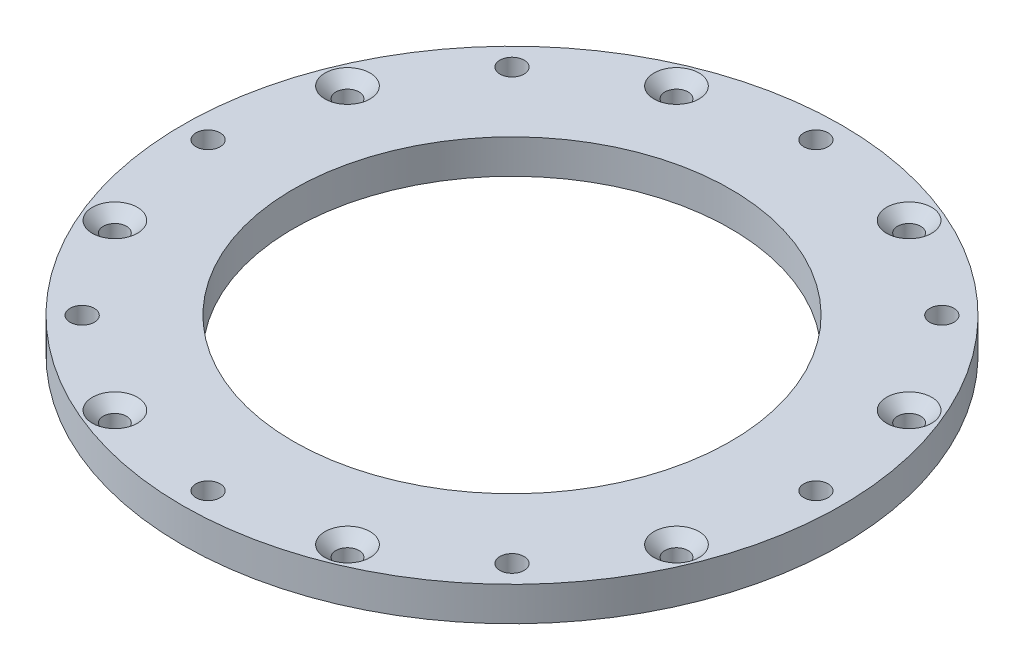
from build123d import *

# Parameters (mm, degrees)
EXTRUDE_1_DEPTH              = 5
SKETCH_2_R                   = 1.525
CUT_EXTRUDE_1_DEPTH          = 6
SKETCH_3_R                   = 48.25
EXTRUDE_2_DEPTH              = 5
SKETCH_4_R                   = 32
CUT_EXTRUDE_2_DEPTH          = 6
FILLET_1_R                   = 40
SKETCH_9_R                   = 7.5
CUT_EXTRUDE_7_DEPTH          = 6
SKETCH_15_R                  = 1.525
CUT_EXTRUDE_10_DEPTH         = 6
SKETCH_16_R                  = 1.525
SKETCH_16_R_2                = 3.525
CUT_EXTRUDE_11_DEPTH         = 6
SKETCH_17_R                  = 1.525
SKETCH_17_R_2                = 3.525
SKETCH_17_R_3                = 7.5
CUT_EXTRUDE_12_DEPTH         = 6
SKETCH_10_R                  = 1.775
CUT_EXTRUDE_13_DEPTH         = 6
SKETCH_19_R                  = 1.525
CUT_EXTRUDE_14_DEPTH         = 6
HOLE_WIZARD_M3_2_D           = 3.4
HOLE_WIZARD_M3_2_CSINK_D     = 6.6
HOLE_WIZARD_M3_2_CSINK_ANGLE = 90


with BuildPart() as part:
    # 草图1 → 凸台-拉伸1 (new body)
    with BuildSketch(Plane(origin=(0, 0, 0), x_dir=(1, 0, 0), z_dir=(0, 1, 0))):
        with BuildLine():
            ThreePointArc((-78.875, 0), (-86.526835342, -18.473164658), (-105, -26.125))
            Line((-105, -26.125), (105, -26.125))
            Line((105, -26.125), (105, 26.125))
            Line((105, 26.125), (-105, 26.125))
            ThreePointArc((-105, 26.125), (-86.526835342, 18.473164658), (-78.875, 0))
        make_face()
        with BuildLine():
            ThreePointArc((-105, 26.125), (-131.125, 0), (-105, -26.125))
            Line((-105, -26.125), (-105, 26.125))
        make_face()
        with BuildLine():
            Line((-105, 26.125), (-105, -26.125))
            ThreePointArc((-105, -26.125), (-86.526835342, -18.473164658), (-78.875, 0))
            ThreePointArc((-78.875, 0), (-86.526835342, 18.473164658), (-105, 26.125))
        make_face()
        with BuildLine():
            ThreePointArc((-105, 26.125), (-131.125, 0), (-105, -26.125))
            Line((-105, -26.125), (-105, 26.125))
        make_face()
        with BuildLine():
            Line((-105, 26.125), (-105, -26.125))
            ThreePointArc((-105, -26.125), (-86.526835342, -18.473164658), (-78.875, 0))
            ThreePointArc((-78.875, 0), (-86.526835342, 18.473164658), (-105, 26.125))
        make_face()
    extrude(amount=EXTRUDE_1_DEPTH)

    # 草图2 → 切除-拉伸1 (cut, through all)
    with BuildSketch(Plane(origin=(0, 5, 0), x_dir=(1, 0, 0), z_dir=(0, 1, 0))):
        with Locations((-91.5, 0)):
            Circle(SKETCH_2_R)
        with Locations((-98.25, -11.691342951)):
            Circle(SKETCH_2_R)
        with Locations((-111.75, -11.691342951)):
            Circle(SKETCH_2_R)
        with Locations((-118.5, 0)):
            Circle(SKETCH_2_R)
        with Locations((-111.75, 11.691342951)):
            Circle(SKETCH_2_R)
        with Locations((-98.25, 11.691342951)):
            Circle(SKETCH_2_R)
    extrude(amount=-CUT_EXTRUDE_1_DEPTH, mode=Mode.SUBTRACT)

    # 草图3 → 凸台-拉伸2 (add)
    with BuildSketch(Plane(origin=(0, 5, 0), x_dir=(1, 0, 0), z_dir=(0, 1, 0))):
        with Locations((105, 0)):
            Circle(SKETCH_3_R)
    extrude(amount=-EXTRUDE_2_DEPTH)

    # 草图4 → 切除-拉伸2 (cut, through all)
    with BuildSketch(Plane(origin=(0, 5, 0), x_dir=(1, 0, 0), z_dir=(0, 1, 0))):
        with Locations((105, 0)):
            Circle(SKETCH_4_R)
    extrude(amount=-CUT_EXTRUDE_2_DEPTH, mode=Mode.SUBTRACT)

    # 圆角1
    fillet_1_edges = [part.edges().sort_by_distance(p)[0] for p in [
        (64.43465919, 2.5, 26.125),
        (64.43465919, 2.5, -26.125),
    ]]
    fillet(fillet_1_edges, radius=FILLET_1_R)

    # 草图9 → 切除-拉伸7 (cut, through all)
    with BuildSketch(Plane(origin=(0, 5, 0), x_dir=(1, 0, 0), z_dir=(0, 1, 0))):
        with Locations((-105, 0)):
            Circle(SKETCH_9_R)
    extrude(amount=-CUT_EXTRUDE_7_DEPTH, mode=Mode.SUBTRACT)

    # 草图15 → 切除-拉伸10 (cut, through all)
    with BuildSketch(Plane(origin=(0, 5, 0), x_dir=(1, 0, 0), z_dir=(0, 1, 0))):
        with Locations((-123.619546181, 10.75)):
            Circle(SKETCH_15_R)
        with Locations((-105, 21.5)):
            Circle(SKETCH_15_R)
        with Locations((-86.380453819, 10.75)):
            Circle(SKETCH_15_R)
        with Locations((-86.380453819, -10.75)):
            Circle(SKETCH_15_R)
        with Locations((-105, -21.5)):
            Circle(SKETCH_15_R)
        with Locations((-123.619546181, -10.75)):
            Circle(SKETCH_15_R)
    extrude(amount=-CUT_EXTRUDE_10_DEPTH, mode=Mode.SUBTRACT)

    # 草图16 → 切除-拉伸11 (cut, through all)
    with BuildSketch(Plane(origin=(0, 5, 0), x_dir=(1, 0, 0), z_dir=(0, 1, 0))):
        with Locations((-111.75, 11.691342951)):
            Circle(SKETCH_16_R)
        with Locations((-111.75, 11.691342951)):
            Circle(SKETCH_16_R_2)
        with Locations((-111.75, 11.691342951)):
            Circle(SKETCH_16_R, mode=Mode.SUBTRACT)
        with Locations((-98.25, 11.691342951)):
            Circle(SKETCH_16_R_2)
        with Locations((-98.25, 11.691342951)):
            Circle(SKETCH_16_R, mode=Mode.SUBTRACT)
        with Locations((-98.25, 11.691342951)):
            Circle(SKETCH_16_R)
        with Locations((-91.5, 0)):
            Circle(SKETCH_16_R)
        with Locations((-91.5, 0)):
            Circle(SKETCH_16_R_2)
        with Locations((-91.5, 0)):
            Circle(SKETCH_16_R, mode=Mode.SUBTRACT)
        with Locations((-98.25, -11.691342951)):
            Circle(SKETCH_16_R_2)
        with Locations((-98.25, -11.691342951)):
            Circle(SKETCH_16_R, mode=Mode.SUBTRACT)
        with Locations((-111.75, -11.691342951)):
            Circle(SKETCH_16_R_2)
        with Locations((-111.75, -11.691342951)):
            Circle(SKETCH_16_R, mode=Mode.SUBTRACT)
        with Locations((-111.75, -11.691342951)):
            Circle(SKETCH_16_R)
        with Locations((-118.5, 0)):
            Circle(SKETCH_16_R_2)
        with Locations((-118.5, 0)):
            Circle(SKETCH_16_R, mode=Mode.SUBTRACT)
        with Locations((-118.5, 0)):
            Circle(SKETCH_16_R)
    extrude(amount=-CUT_EXTRUDE_11_DEPTH, mode=Mode.SUBTRACT)

    # 草图17 → 切除-拉伸12 (cut, through all)
    with BuildSketch(Plane(origin=(0, 5, 0), x_dir=(1, 0, 0), z_dir=(0, 1, 0))):
        with BuildLine():
            ThreePointArc((-105, 26.125), (-131.125, 0), (-105, -26.125))
            Line((-105, -26.125), (46.557319748, -26.125))
            ThreePointArc((46.557319748, -26.125), (60.719472559, -28.715998038), (73.046919862, -36.153328612))
            ThreePointArc((73.046919862, -36.153328612), (56.75, 0), (73.046919862, 36.153328612))
            ThreePointArc((73.046919862, 36.153328612), (60.719472559, 28.715998038), (46.557319748, 26.125))
            Line((46.557319748, 26.125), (-105, 26.125))
        make_face()
        with Locations((-105, -21.5)):
            Circle(SKETCH_17_R, mode=Mode.SUBTRACT)
        with Locations((-123.619546181, -10.75)):
            Circle(SKETCH_17_R, mode=Mode.SUBTRACT)
        with Locations((-111.75, -11.691342951)):
            Circle(SKETCH_17_R_2, mode=Mode.SUBTRACT)
        with Locations((-98.25, -11.691342951)):
            Circle(SKETCH_17_R_2, mode=Mode.SUBTRACT)
        with Locations((-118.5, 0)):
            Circle(SKETCH_17_R_2, mode=Mode.SUBTRACT)
        with Locations((-105, 0)):
            Circle(SKETCH_17_R_3, mode=Mode.SUBTRACT)
        with Locations((-86.380453819, -10.75)):
            Circle(SKETCH_17_R, mode=Mode.SUBTRACT)
        with Locations((-123.619546181, 10.75)):
            Circle(SKETCH_17_R, mode=Mode.SUBTRACT)
        with Locations((-111.75, 11.691342951)):
            Circle(SKETCH_17_R_2, mode=Mode.SUBTRACT)
        with Locations((-98.25, 11.691342951)):
            Circle(SKETCH_17_R_2, mode=Mode.SUBTRACT)
        with Locations((-91.5, 0)):
            Circle(SKETCH_17_R_2, mode=Mode.SUBTRACT)
        with Locations((-86.380453819, 10.75)):
            Circle(SKETCH_17_R, mode=Mode.SUBTRACT)
        with Locations((-105, 21.5)):
            Circle(SKETCH_17_R, mode=Mode.SUBTRACT)
    extrude(amount=-CUT_EXTRUDE_12_DEPTH, mode=Mode.SUBTRACT)

    # 草图10 → 切除-拉伸13 (cut, through all)
    with BuildSketch(Plane(origin=(0, 5, 0), x_dir=(1, 0, 0), z_dir=(0, 1, 0))):
        with Locations((73.533748237, 31.466251763)):
            Circle(SKETCH_10_R)
        with Locations((105, 44.5)):
            Circle(SKETCH_10_R)
        with Locations((136.466251763, 31.466251763)):
            Circle(SKETCH_10_R)
        with Locations((136.466251763, -31.466251763)):
            Circle(SKETCH_10_R)
        with Locations((73.533748237, -31.466251763)):
            Circle(SKETCH_10_R)
        with Locations((60.5, 0)):
            Circle(SKETCH_10_R)
        with Locations((149.5, 0)):
            Circle(SKETCH_10_R)
        with Locations((105, -44.5)):
            Circle(SKETCH_10_R)
    extrude(amount=-CUT_EXTRUDE_13_DEPTH, mode=Mode.SUBTRACT)

    # 草图19 → 切除-拉伸14 (cut, through all)
    with BuildSketch(Plane(origin=(0, 5, 0), x_dir=(1, 0, 0), z_dir=(0, 1, 0))):
        with Locations((122.02941274, 41.112639197)):
            Circle(SKETCH_19_R)
        with Locations((146.112639197, 17.02941274)):
            Circle(SKETCH_19_R)
        with Locations((146.112639197, -17.02941274)):
            Circle(SKETCH_19_R)
        with Locations((122.02941274, -41.112639197)):
            Circle(SKETCH_19_R)
        with Locations((87.97058726, -41.112639197)):
            Circle(SKETCH_19_R)
        with Locations((63.887360803, -17.02941274)):
            Circle(SKETCH_19_R)
        with Locations((63.887360803, 17.02941274)):
            Circle(SKETCH_19_R)
        with Locations((87.97058726, 41.112639197)):
            Circle(SKETCH_19_R)
    extrude(amount=-CUT_EXTRUDE_14_DEPTH, mode=Mode.SUBTRACT)

    # M3 开槽沉头木螺钉的锥形沉头孔2 (through all)
    with Locations(Plane(origin=(0, 5, 0), x_dir=(1, 0, 0), z_dir=(0, 1, 0))):
        with Locations((87.97058726, 41.112639197), (122.02941274, 41.112639197), (146.112639197, 17.02941274), (146.112639197, -17.02941274), (122.02941274, -41.112639197), (87.97058726, -41.112639197), (63.887360803, -17.02941274), (63.887360803, 17.02941274)):
            CounterSinkHole(HOLE_WIZARD_M3_2_D / 2, HOLE_WIZARD_M3_2_CSINK_D / 2, counter_sink_angle=HOLE_WIZARD_M3_2_CSINK_ANGLE)


solid = part.part
